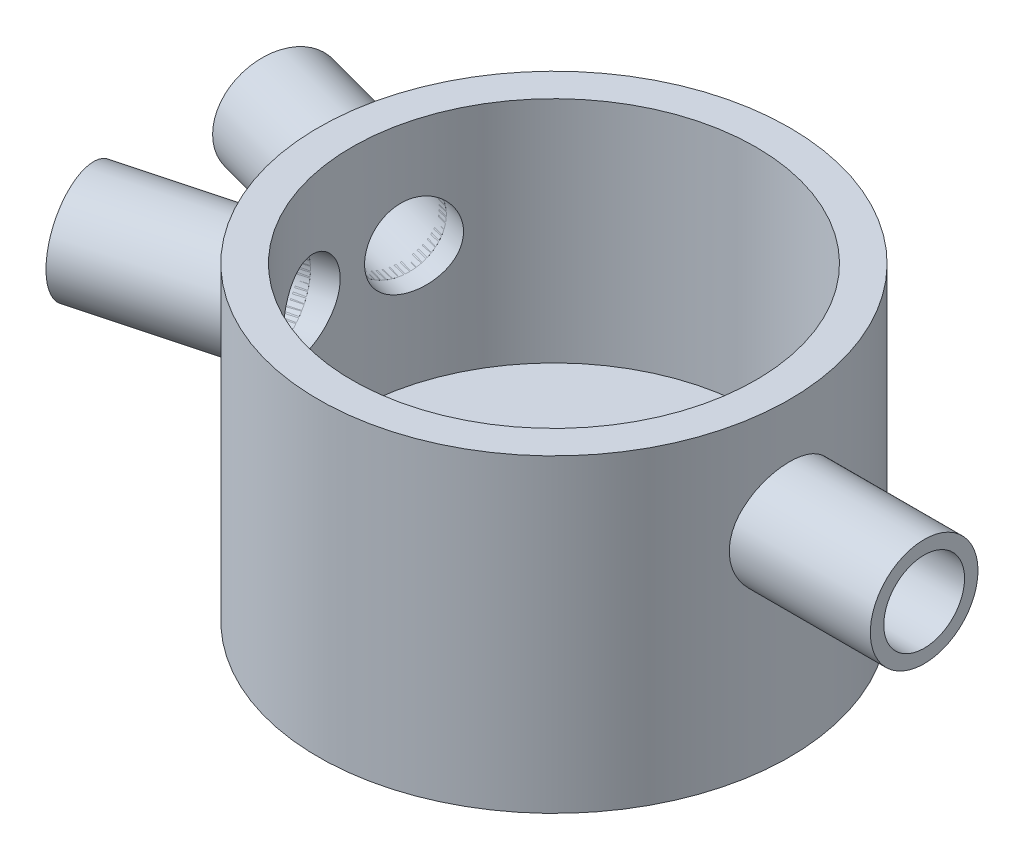
from build123d import *

# Parameters (mm, degrees)
FUROS_GUIA_COM_6_0MM1_D       = 6
FUROS_GUIA_COM_6_0MM1_DEPTH   = 5
FUROS_GUIA_COM_6_0MM1_TIP     = 1.802581857
FUROS_GUIA_COM_6_0MM5_D       = 6
FUROS_GUIA_COM_6_0MM5_DEPTH   = 5
FUROS_GUIA_COM_6_0MM5_TIP     = 1.802581857
FUROS_GUIA_COM_6_0MM4_D       = 6
FUROS_GUIA_COM_6_0MM4_DEPTH   = 5
FUROS_GUIA_COM_6_0MM4_TIP     = 1.802581857
ESBO_O9_R                     = 4
ESBO_O9_R_2                   = 3
RESSALTO_EXTRUS_O1_DEPTH      = 11.432571
RESSALTO_EXTRUS_O1_DEPTH_BACK = 1
ESBO_O11_R                    = 4
ESBO_O11_R_2                  = 3
RESSALTO_EXTRUS_O2_DEPTH      = 11
RESSALTO_EXTRUS_O2_DEPTH_BACK = 1
ESBO_O13_R                    = 4
ESBO_O13_R_2                  = 3
RESSALTO_EXTRUS_O3_DEPTH      = 10
RESSALTO_EXTRUS_O3_DEPTH_BACK = 1


with BuildPart() as part:
    # Esbo_o1 → Revolu_o1 (revolve)
    with BuildSketch(Plane.XY):
        Polygon((0, -15), (17.5, -15), (17.5, 8), (15, 8), (15, -9), (5, -9), (5, -11.5), (3.25, -11.5), (3.25, -12.5), (0, -12.5), align=None)
    revolve(axis=Axis((0, 0, 0), (0, 1, 0)))

    # Furos-guia com _6.0mm1
    with Locations(Plane(origin=(17.5, 0, 0), x_dir=(0, 0, 1), z_dir=(1, 0, 0))):
        with Locations((0, 0)):
            Hole(FUROS_GUIA_COM_6_0MM1_D / 2, depth=FUROS_GUIA_COM_6_0MM1_DEPTH)
            with Locations((0, 0, -(FUROS_GUIA_COM_6_0MM1_DEPTH + FUROS_GUIA_COM_6_0MM1_TIP / 2))):  # 118° drill point
                Cone(0, FUROS_GUIA_COM_6_0MM1_D / 2, FUROS_GUIA_COM_6_0MM1_TIP, mode=Mode.SUBTRACT)

    # Furos-guia com _6.0mm5
    with Locations(Plane(origin=(-16.90370196, 0, -4.529333289), x_dir=(0.258819045, 0, -0.965925826), z_dir=(-0.965925826, 0, -0.258819045))):
        with Locations((0, 0)):
            Hole(FUROS_GUIA_COM_6_0MM5_D / 2, depth=FUROS_GUIA_COM_6_0MM5_DEPTH)
            with Locations((0, 0, -(FUROS_GUIA_COM_6_0MM5_DEPTH + FUROS_GUIA_COM_6_0MM5_TIP / 2))):  # 118° drill point
                Cone(0, FUROS_GUIA_COM_6_0MM5_D / 2, FUROS_GUIA_COM_6_0MM5_TIP, mode=Mode.SUBTRACT)

    # Furos-guia com _6.0mm4
    with Locations(Plane(origin=(-16.90370196, 0, 4.529333289), x_dir=(-0.258819045, 0, -0.965925826), z_dir=(-0.965925826, 0, 0.258819045))):
        with Locations((0, 0)):
            Hole(FUROS_GUIA_COM_6_0MM4_D / 2, depth=FUROS_GUIA_COM_6_0MM4_DEPTH)
            with Locations((0, 0, -(FUROS_GUIA_COM_6_0MM4_DEPTH + FUROS_GUIA_COM_6_0MM4_TIP / 2))):  # 118° drill point
                Cone(0, FUROS_GUIA_COM_6_0MM4_D / 2, FUROS_GUIA_COM_6_0MM4_TIP, mode=Mode.SUBTRACT)


with BuildPart() as body_2:
    # Esbo_o9 → Ressalto-extrus_o1 (new body, two sides)
    with BuildSketch(Plane(origin=(-16.90370196, 0, -4.529333289), x_dir=(0, -1, 0), z_dir=(-0.965925826, 0, -0.258819045))) as ressalto_extrus_o1_sk:
        Circle(ESBO_O9_R)
        Circle(ESBO_O9_R_2, mode=Mode.SUBTRACT)
    extrude(amount=RESSALTO_EXTRUS_O1_DEPTH)
    extrude(ressalto_extrus_o1_sk.sketch, amount=-RESSALTO_EXTRUS_O1_DEPTH_BACK)


with BuildPart() as body_3:
    # Esbo_o11 → Ressalto-extrus_o2 (new body, two sides)
    with BuildSketch(Plane(origin=(-16.90370196, 0, 4.529333289), x_dir=(0, -1, 0), z_dir=(-0.965925826, 0, 0.258819045))) as ressalto_extrus_o2_sk:
        Circle(ESBO_O11_R)
        Circle(ESBO_O11_R_2, mode=Mode.SUBTRACT)
    extrude(amount=RESSALTO_EXTRUS_O2_DEPTH)
    extrude(ressalto_extrus_o2_sk.sketch, amount=-RESSALTO_EXTRUS_O2_DEPTH_BACK)


with BuildPart() as body_4:
    # Esbo_o13 → Ressalto-extrus_o3 (new body, two sides)
    with BuildSketch(Plane(origin=(17.5, 0, 0), x_dir=(0, -1, 0), z_dir=(1, 0, 0))) as ressalto_extrus_o3_sk:
        Circle(ESBO_O13_R)
        Circle(ESBO_O13_R_2, mode=Mode.SUBTRACT)
    extrude(amount=RESSALTO_EXTRUS_O3_DEPTH)
    extrude(ressalto_extrus_o3_sk.sketch, amount=-RESSALTO_EXTRUS_O3_DEPTH_BACK)


solid = Compound([part.part, body_2.part, body_3.part, body_4.part])
